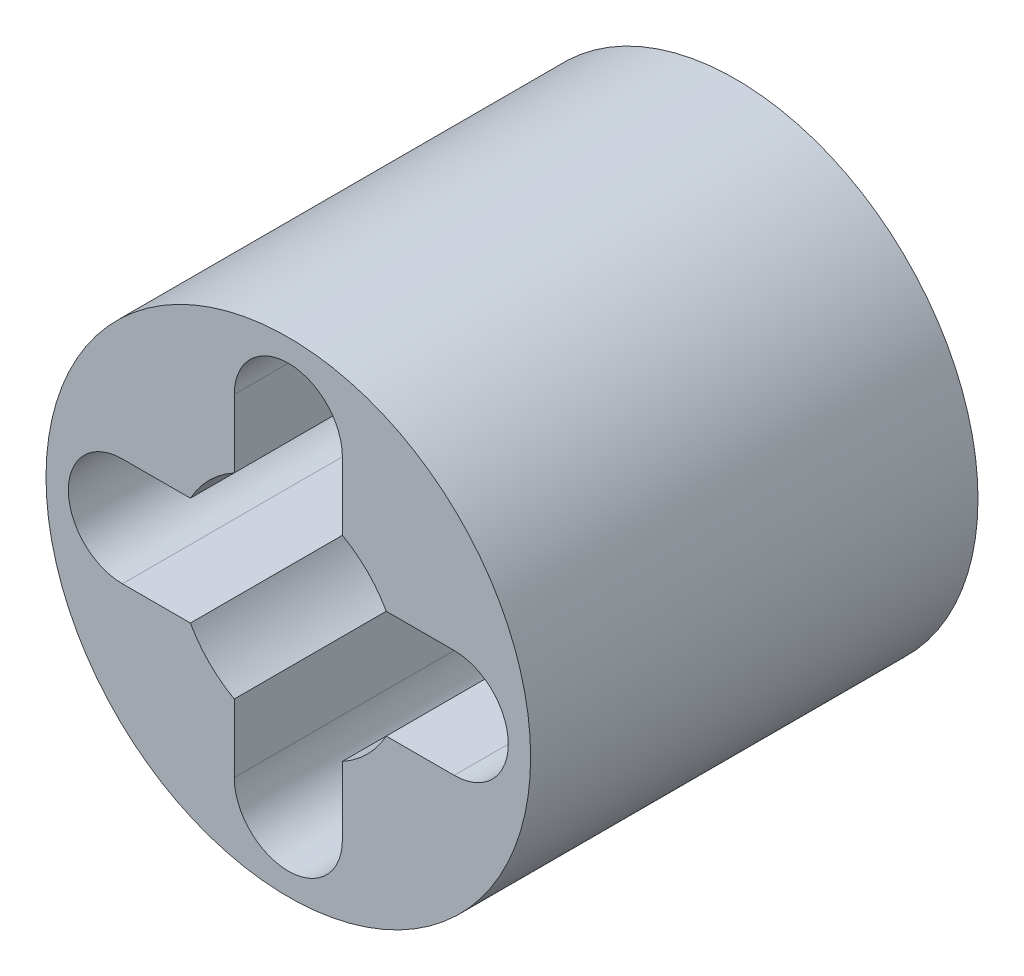
from build123d import *

# Parameters (mm, degrees)
ESQUISSE1_R        = 3.25
BOSS_EXTRU_1_DEPTH = 6


with BuildPart() as part:
    # Esquisse1 → Boss.-Extru.1 (new body)
    with BuildSketch(Plane.XY):
        Circle(ESQUISSE1_R)
        with BuildLine():
            Line((2.225, -0.725), (1.313154599, -0.725))
            ThreePointArc((1.313154599, -0.725), (1.060660172, -1.060660172), (0.725, -1.313154599))
            Line((0.725, -1.313154599), (0.725, -2.225))
            ThreePointArc((0.725, -2.225), (0, -2.95), (-0.725, -2.225))
            Line((-0.725, -2.225), (-0.725, -1.313154599))
            ThreePointArc((-0.725, -1.313154599), (-1.060660172, -1.060660172), (-1.313154599, -0.725))
            Line((-1.313154599, -0.725), (-2.225, -0.725))
            ThreePointArc((-2.225, -0.725), (-2.95, 0), (-2.225, 0.725))
            Line((-2.225, 0.725), (-1.313154599, 0.725))
            ThreePointArc((-1.313154599, 0.725), (-1.060660172, 1.060660172), (-0.725, 1.313154599))
            Line((-0.725, 1.313154599), (-0.725, 2.225))
            ThreePointArc((-0.725, 2.225), (0, 2.95), (0.725, 2.225))
            Line((0.725, 2.225), (0.725, 1.313154599))
            ThreePointArc((0.725, 1.313154599), (1.060660172, 1.060660172), (1.313154599, 0.725))
            Line((1.313154599, 0.725), (2.225, 0.725))
            ThreePointArc((2.225, 0.725), (2.95, 0), (2.225, -0.725))
        make_face(mode=Mode.SUBTRACT)
    extrude(amount=BOSS_EXTRU_1_DEPTH)


solid = part.part
